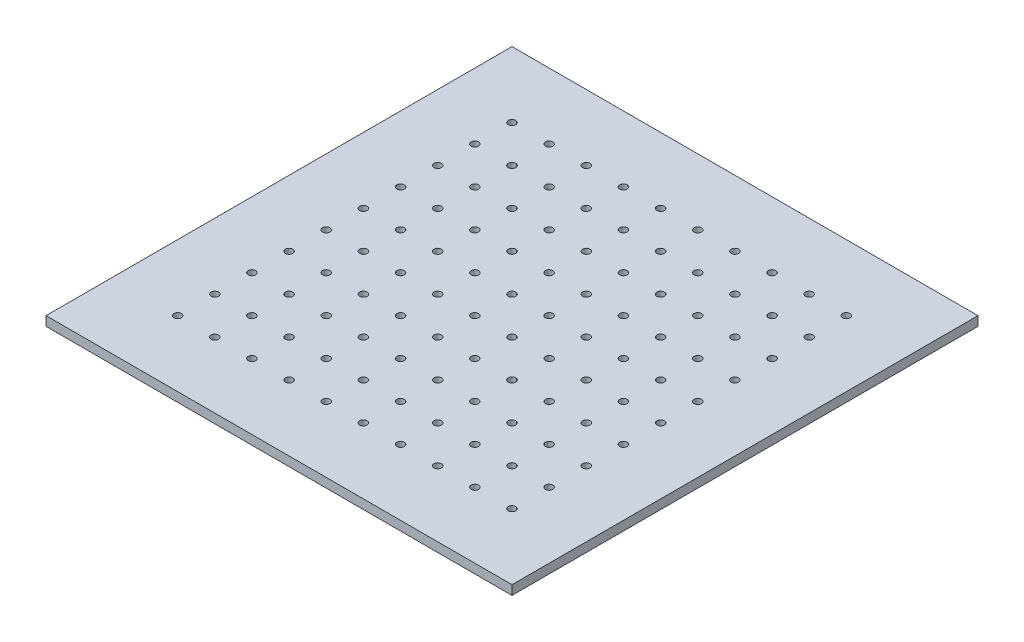
from build123d import *

# Parameters (mm, degrees)
SKETCH1_W           = 318.6
SKETCH1_H           = 318.6
SKETCH1_R           = 2.5527
BOSS_EXTRUDE1_DEPTH = 6.35


with BuildPart() as part:
    # Sketch1 → Boss-Extrude1 (new body)
    with BuildSketch(Plane(origin=(0, 0, 0), x_dir=(1, 0, 0), z_dir=(0, 1, 0))):
        with Locations((114.3, 114.3)):
            Rectangle(SKETCH1_W, SKETCH1_H)
        Circle(SKETCH1_R, mode=Mode.SUBTRACT)
        with Locations((25.4, 0)):
            Circle(SKETCH1_R, mode=Mode.SUBTRACT)
        with Locations((50.8, 0)):
            Circle(SKETCH1_R, mode=Mode.SUBTRACT)
        with Locations((76.2, 0)):
            Circle(SKETCH1_R, mode=Mode.SUBTRACT)
        with Locations((101.6, 0)):
            Circle(SKETCH1_R, mode=Mode.SUBTRACT)
        with Locations((127, 0)):
            Circle(SKETCH1_R, mode=Mode.SUBTRACT)
        with Locations((152.4, 0)):
            Circle(SKETCH1_R, mode=Mode.SUBTRACT)
        with Locations((177.8, 0)):
            Circle(SKETCH1_R, mode=Mode.SUBTRACT)
        with Locations((203.2, 0)):
            Circle(SKETCH1_R, mode=Mode.SUBTRACT)
        with Locations((228.6, 0)):
            Circle(SKETCH1_R, mode=Mode.SUBTRACT)
        with Locations((0, 25.4)):
            Circle(SKETCH1_R, mode=Mode.SUBTRACT)
        with Locations((25.4, 25.4)):
            Circle(SKETCH1_R, mode=Mode.SUBTRACT)
        with Locations((50.8, 25.4)):
            Circle(SKETCH1_R, mode=Mode.SUBTRACT)
        with Locations((76.2, 25.4)):
            Circle(SKETCH1_R, mode=Mode.SUBTRACT)
        with Locations((101.6, 25.4)):
            Circle(SKETCH1_R, mode=Mode.SUBTRACT)
        with Locations((127, 25.4)):
            Circle(SKETCH1_R, mode=Mode.SUBTRACT)
        with Locations((152.4, 25.4)):
            Circle(SKETCH1_R, mode=Mode.SUBTRACT)
        with Locations((177.8, 25.4)):
            Circle(SKETCH1_R, mode=Mode.SUBTRACT)
        with Locations((203.2, 25.4)):
            Circle(SKETCH1_R, mode=Mode.SUBTRACT)
        with Locations((228.6, 25.4)):
            Circle(SKETCH1_R, mode=Mode.SUBTRACT)
        with Locations((0, 50.8)):
            Circle(SKETCH1_R, mode=Mode.SUBTRACT)
        with Locations((25.4, 50.8)):
            Circle(SKETCH1_R, mode=Mode.SUBTRACT)
        with Locations((50.8, 50.8)):
            Circle(SKETCH1_R, mode=Mode.SUBTRACT)
        with Locations((76.2, 50.8)):
            Circle(SKETCH1_R, mode=Mode.SUBTRACT)
        with Locations((101.6, 50.8)):
            Circle(SKETCH1_R, mode=Mode.SUBTRACT)
        with Locations((127, 50.8)):
            Circle(SKETCH1_R, mode=Mode.SUBTRACT)
        with Locations((152.4, 50.8)):
            Circle(SKETCH1_R, mode=Mode.SUBTRACT)
        with Locations((177.8, 50.8)):
            Circle(SKETCH1_R, mode=Mode.SUBTRACT)
        with Locations((203.2, 50.8)):
            Circle(SKETCH1_R, mode=Mode.SUBTRACT)
        with Locations((228.6, 50.8)):
            Circle(SKETCH1_R, mode=Mode.SUBTRACT)
        with Locations((0, 76.2)):
            Circle(SKETCH1_R, mode=Mode.SUBTRACT)
        with Locations((25.4, 76.2)):
            Circle(SKETCH1_R, mode=Mode.SUBTRACT)
        with Locations((50.8, 76.2)):
            Circle(SKETCH1_R, mode=Mode.SUBTRACT)
        with Locations((76.2, 76.2)):
            Circle(SKETCH1_R, mode=Mode.SUBTRACT)
        with Locations((101.6, 76.2)):
            Circle(SKETCH1_R, mode=Mode.SUBTRACT)
        with Locations((127, 76.2)):
            Circle(SKETCH1_R, mode=Mode.SUBTRACT)
        with Locations((152.4, 76.2)):
            Circle(SKETCH1_R, mode=Mode.SUBTRACT)
        with Locations((177.8, 76.2)):
            Circle(SKETCH1_R, mode=Mode.SUBTRACT)
        with Locations((203.2, 76.2)):
            Circle(SKETCH1_R, mode=Mode.SUBTRACT)
        with Locations((228.6, 76.2)):
            Circle(SKETCH1_R, mode=Mode.SUBTRACT)
        with Locations((0, 101.6)):
            Circle(SKETCH1_R, mode=Mode.SUBTRACT)
        with Locations((25.4, 101.6)):
            Circle(SKETCH1_R, mode=Mode.SUBTRACT)
        with Locations((50.8, 101.6)):
            Circle(SKETCH1_R, mode=Mode.SUBTRACT)
        with Locations((76.2, 101.6)):
            Circle(SKETCH1_R, mode=Mode.SUBTRACT)
        with Locations((101.6, 101.6)):
            Circle(SKETCH1_R, mode=Mode.SUBTRACT)
        with Locations((127, 101.6)):
            Circle(SKETCH1_R, mode=Mode.SUBTRACT)
        with Locations((152.4, 101.6)):
            Circle(SKETCH1_R, mode=Mode.SUBTRACT)
        with Locations((177.8, 101.6)):
            Circle(SKETCH1_R, mode=Mode.SUBTRACT)
        with Locations((203.2, 101.6)):
            Circle(SKETCH1_R, mode=Mode.SUBTRACT)
        with Locations((228.6, 101.6)):
            Circle(SKETCH1_R, mode=Mode.SUBTRACT)
        with Locations((0, 127)):
            Circle(SKETCH1_R, mode=Mode.SUBTRACT)
        with Locations((25.4, 127)):
            Circle(SKETCH1_R, mode=Mode.SUBTRACT)
        with Locations((50.8, 127)):
            Circle(SKETCH1_R, mode=Mode.SUBTRACT)
        with Locations((76.2, 127)):
            Circle(SKETCH1_R, mode=Mode.SUBTRACT)
        with Locations((101.6, 127)):
            Circle(SKETCH1_R, mode=Mode.SUBTRACT)
        with Locations((127, 127)):
            Circle(SKETCH1_R, mode=Mode.SUBTRACT)
        with Locations((152.4, 127)):
            Circle(SKETCH1_R, mode=Mode.SUBTRACT)
        with Locations((177.8, 127)):
            Circle(SKETCH1_R, mode=Mode.SUBTRACT)
        with Locations((203.2, 127)):
            Circle(SKETCH1_R, mode=Mode.SUBTRACT)
        with Locations((228.6, 127)):
            Circle(SKETCH1_R, mode=Mode.SUBTRACT)
        with Locations((0, 152.4)):
            Circle(SKETCH1_R, mode=Mode.SUBTRACT)
        with Locations((25.4, 152.4)):
            Circle(SKETCH1_R, mode=Mode.SUBTRACT)
        with Locations((50.8, 152.4)):
            Circle(SKETCH1_R, mode=Mode.SUBTRACT)
        with Locations((76.2, 152.4)):
            Circle(SKETCH1_R, mode=Mode.SUBTRACT)
        with Locations((101.6, 152.4)):
            Circle(SKETCH1_R, mode=Mode.SUBTRACT)
        with Locations((127, 152.4)):
            Circle(SKETCH1_R, mode=Mode.SUBTRACT)
        with Locations((152.4, 152.4)):
            Circle(SKETCH1_R, mode=Mode.SUBTRACT)
        with Locations((177.8, 152.4)):
            Circle(SKETCH1_R, mode=Mode.SUBTRACT)
        with Locations((203.2, 152.4)):
            Circle(SKETCH1_R, mode=Mode.SUBTRACT)
        with Locations((228.6, 152.4)):
            Circle(SKETCH1_R, mode=Mode.SUBTRACT)
        with Locations((0, 177.8)):
            Circle(SKETCH1_R, mode=Mode.SUBTRACT)
        with Locations((25.4, 177.8)):
            Circle(SKETCH1_R, mode=Mode.SUBTRACT)
        with Locations((50.8, 177.8)):
            Circle(SKETCH1_R, mode=Mode.SUBTRACT)
        with Locations((76.2, 177.8)):
            Circle(SKETCH1_R, mode=Mode.SUBTRACT)
        with Locations((101.6, 177.8)):
            Circle(SKETCH1_R, mode=Mode.SUBTRACT)
        with Locations((127, 177.8)):
            Circle(SKETCH1_R, mode=Mode.SUBTRACT)
        with Locations((152.4, 177.8)):
            Circle(SKETCH1_R, mode=Mode.SUBTRACT)
        with Locations((177.8, 177.8)):
            Circle(SKETCH1_R, mode=Mode.SUBTRACT)
        with Locations((203.2, 177.8)):
            Circle(SKETCH1_R, mode=Mode.SUBTRACT)
        with Locations((228.6, 177.8)):
            Circle(SKETCH1_R, mode=Mode.SUBTRACT)
        with Locations((0, 203.2)):
            Circle(SKETCH1_R, mode=Mode.SUBTRACT)
        with Locations((25.4, 203.2)):
            Circle(SKETCH1_R, mode=Mode.SUBTRACT)
        with Locations((50.8, 203.2)):
            Circle(SKETCH1_R, mode=Mode.SUBTRACT)
        with Locations((76.2, 203.2)):
            Circle(SKETCH1_R, mode=Mode.SUBTRACT)
        with Locations((101.6, 203.2)):
            Circle(SKETCH1_R, mode=Mode.SUBTRACT)
        with Locations((127, 203.2)):
            Circle(SKETCH1_R, mode=Mode.SUBTRACT)
        with Locations((152.4, 203.2)):
            Circle(SKETCH1_R, mode=Mode.SUBTRACT)
        with Locations((177.8, 203.2)):
            Circle(SKETCH1_R, mode=Mode.SUBTRACT)
        with Locations((203.2, 203.2)):
            Circle(SKETCH1_R, mode=Mode.SUBTRACT)
        with Locations((228.6, 203.2)):
            Circle(SKETCH1_R, mode=Mode.SUBTRACT)
        with Locations((0, 228.6)):
            Circle(SKETCH1_R, mode=Mode.SUBTRACT)
        with Locations((25.4, 228.6)):
            Circle(SKETCH1_R, mode=Mode.SUBTRACT)
        with Locations((50.8, 228.6)):
            Circle(SKETCH1_R, mode=Mode.SUBTRACT)
        with Locations((76.2, 228.6)):
            Circle(SKETCH1_R, mode=Mode.SUBTRACT)
        with Locations((101.6, 228.6)):
            Circle(SKETCH1_R, mode=Mode.SUBTRACT)
        with Locations((127, 228.6)):
            Circle(SKETCH1_R, mode=Mode.SUBTRACT)
        with Locations((152.4, 228.6)):
            Circle(SKETCH1_R, mode=Mode.SUBTRACT)
        with Locations((177.8, 228.6)):
            Circle(SKETCH1_R, mode=Mode.SUBTRACT)
        with Locations((203.2, 228.6)):
            Circle(SKETCH1_R, mode=Mode.SUBTRACT)
        with Locations((228.6, 228.6)):
            Circle(SKETCH1_R, mode=Mode.SUBTRACT)
    extrude(amount=BOSS_EXTRUDE1_DEPTH)


solid = part.part
